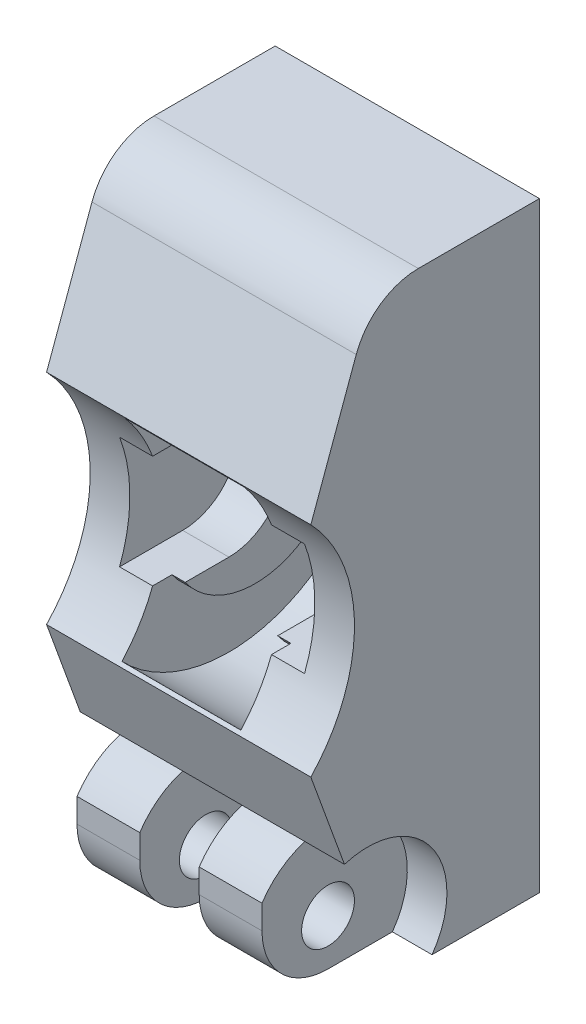
from build123d import *

# Parameters (mm, degrees)
BOSS_EXTRU_1_DEPTH      = 20
ENL_V_MAT_EXTRU_1_REACH = 22
ESQUISSE2_R             = 2
ESQUISSE2_R_2           = 12
ENL_V_START             = -3
ENL_V_MAT_EXTRU_7_DEPTH = 14
CONG_1_R                = 5
ESQUISSE5_R             = 11.25
ENL_V_MAT_EXTRU_2_DEPTH = 4.5
BOSS_EXTRU_2_DEPTH      = 1
ESQUISSE11_R            = 6
ENL_V_MAT_EXTRU_3_DEPTH = 2.25
ENL_V_START_2           = 10
ENL_V_MAT_EXTRU_4_DEPTH = 3
ENL_V_START_3           = -7
ESQUISSE11_3_R          = 6
ENL_V_MAT_EXTRU_5_DEPTH = 3
ENL_V_MAT_EXTRU_6_DEPTH = 20


with BuildPart() as part:
    # Esquisse1 → Boss.-Extru.1 (new body)
    with BuildSketch(Plane(origin=(0, 0, 0), x_dir=(0, 0, -1), z_dir=(1, 0, 0))):
        Polygon((0, 22.75), (0, -22.75), (-18, -22.75), (-18, -8.1), (-18, 8.1), (-12.667836068, 22.75), align=None)
    extrude(amount=BOSS_EXTRU_1_DEPTH)

    # Esquisse2 → Enl_v. mat.-Extru.1 (cut, up to next)
    with BuildSketch(Plane.ZY, mode=Mode.PRIVATE) as enl_v_mat_extru_1_sk1:
        with Locations((13, -19.25)):
            Circle(ESQUISSE2_R)
    enl_v_mat_extru_1_tool1 = extrude(enl_v_mat_extru_1_sk1.sketch, amount=-ENL_V_MAT_EXTRU_1_REACH, mode=Mode.PRIVATE) & part.part
    add(enl_v_mat_extru_1_tool1.solids().sort_by_distance((0, -19.25, 13))[0], mode=Mode.SUBTRACT)
    # Esquisse2 → Enl_v. mat.-Extru.1 (cut, up to next)
    with BuildSketch(Plane.ZY, mode=Mode.PRIVATE) as enl_v_mat_extru_1_sk2:
        with Locations((26, 1.75)):
            Circle(ESQUISSE2_R_2)
    enl_v_mat_extru_1_tool2 = extrude(enl_v_mat_extru_1_sk2.sketch, amount=-ENL_V_MAT_EXTRU_1_REACH, mode=Mode.PRIVATE) & part.part
    add(enl_v_mat_extru_1_tool2.solids().sort_by_distance((0, 1.75, 26))[0], mode=Mode.SUBTRACT)

    # Esquisse14 → Enl_v. mat.-Extru.7 (cut)
    with BuildSketch(Plane.ZY.offset(ENL_V_START)):
        with BuildLine():
            Line((10, 6), (14.777812156, 6))
            ThreePointArc((14.777812156, 6), (14, 1.75), (14.777812156, -2.5))
            Line((14.777812156, -2.5), (10, -2.5))
            ThreePointArc((10, -2.5), (5.75, 1.75), (10, 6))
        make_face()
    extrude(amount=-ENL_V_MAT_EXTRU_7_DEPTH, mode=Mode.SUBTRACT)

    # Cong_1
    cong_1_edges = [part.edges().sort_by_distance(p)[0] for p in [
        (10, -22.75, 18),
        (10, 22.75, 12.667836068),
    ]]
    fillet(cong_1_edges, radius=CONG_1_R)

    # Esquisse5 → Enl_v. mat.-Extru.2 (cut, symmetric)
    with BuildSketch(Plane.ZY.offset(-10)):
        with Locations((9.002244805, 1.517900266)):
            Circle(ESQUISSE5_R)
    extrude(amount=ENL_V_MAT_EXTRU_2_DEPTH, both=True, mode=Mode.SUBTRACT)

    # Esquisse8 → Boss.-Extru.2 (add)
    with BuildSketch(Plane(origin=(5.5, 0, 0), x_dir=(0, 0, -1), z_dir=(1, 0, 0))):
        with BuildLine():
            Line((-12.461710624, 6), (-10, 6))
            ThreePointArc((-10, 6), (-5.75, 1.75), (-10, -2.5))
            Line((-10, -2.5), (-13.309218442, -2.5))
            ThreePointArc((-13.309218442, -2.5), (-6.034488781, -4.92870357), (-1.509850884, 1.263868155))
            ThreePointArc((-1.509850884, 1.263868155), (-5.429840061, 7.229900685), (-12.461710624, 6))
        make_face()
    boss_extru_2 = extrude(amount=BOSS_EXTRU_2_DEPTH)

    # Sym_trie1: Boss.-Extru.2 across plane
    add(boss_extru_2.mirror(Plane.ZY.offset(-10)))

    # Esquisse11 → Enl_v. mat.-Extru.3 (cut, symmetric)
    with BuildSketch(Plane.ZY.offset(-10)):
        with Locations((13, -19.25)):
            Circle(ESQUISSE11_R)
    extrude(amount=ENL_V_MAT_EXTRU_3_DEPTH, both=True, mode=Mode.SUBTRACT)

    # Esquisse11 → Enl_v. mat.-Extru.4 (cut)
    with BuildSketch(Plane.ZY.offset(-10).offset(ENL_V_START_2)):
        with Locations((13, -19.25)):
            Circle(ESQUISSE11_R)
    extrude(amount=-ENL_V_MAT_EXTRU_4_DEPTH, mode=Mode.SUBTRACT)

    # Esquisse11_3 → Enl_v. mat.-Extru.5 (cut)
    with BuildSketch(Plane.ZY.offset(-10).offset(ENL_V_START_3)):
        with Locations((13, -19.25)):
            Circle(ESQUISSE11_3_R)
    extrude(amount=-ENL_V_MAT_EXTRU_5_DEPTH, mode=Mode.SUBTRACT)

    # Esquisse13 → Enl_v. mat.-Extru.6 (cut)
    with BuildSketch(Plane.ZY):
        with BuildLine():
            Line((18, -7.19427191), (17.30217057, -6.517270602))
            Line((17.30217057, -6.517270602), (14.75603403, -13.512723252))
            ThreePointArc((14.75603403, -13.512723252), (16.588298751, -14.441246308), (18, -15.93337521))
            Line((18, -15.93337521), (18, -7.19427191))
        make_face()
    extrude(amount=-ENL_V_MAT_EXTRU_6_DEPTH, mode=Mode.SUBTRACT)


solid = part.part
